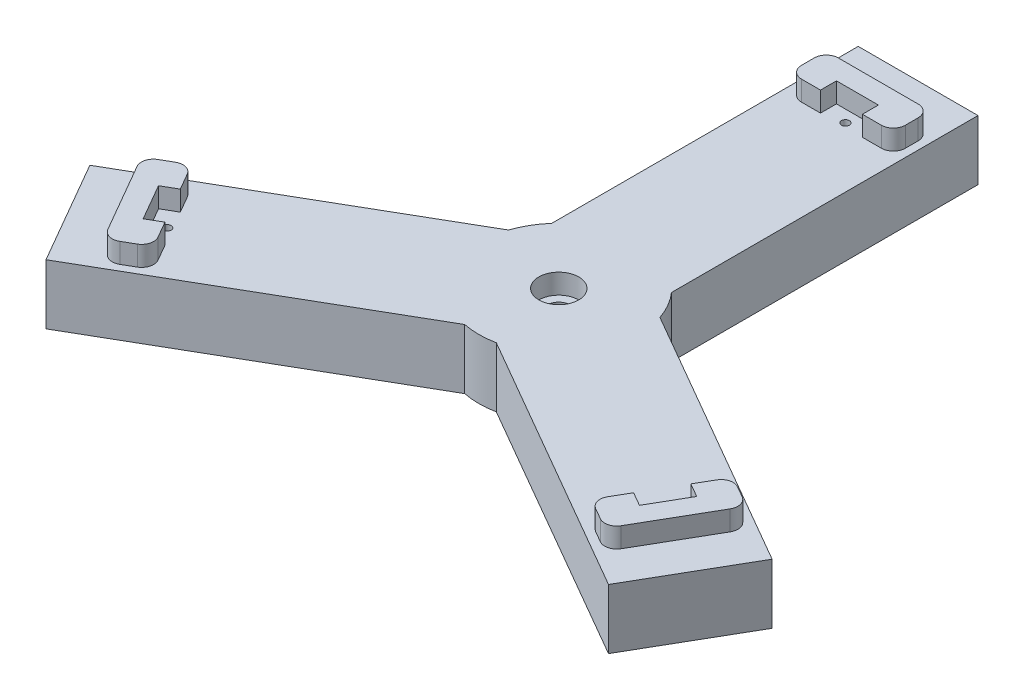
from build123d import *

# Parameters (mm, degrees)
SKETCH5_R                = 20
BOSS_EXTRUDE2_DEPTH      = 15
SKETCH6_W                = 30
SKETCH6_H                = 90
BOSS_EXTRUDE3_DEPTH      = 15
CIRPATTERN1_COUNT        = 3
BOSS_EXTRUDE4_DEPTH      = 5
FILLET1_R                = 3
SKETCH8_R                = 1
CUT_EXTRUDE1_DEPTH       = 16
SKETCH9_R                = 10
CUT_EXTRUDE2_DEPTH       = 10
CIRPATTERN4_COUNT        = 3
FILLET1_OF_CIRPATTERN4_R = 3
CIRPATTERN6_COUNT        = 3
CUT_EXTRUDE4_REACH       = 22
SKETCH11_R               = 2.875
SKETCH13_W               = 18
SKETCH13_H               = 18
CUT_EXTRUDE5_DEPTH       = 5
FILLET2_R                = 5
SKETCH14_R               = 5
CUT_EXTRUDE6_DEPTH       = 5


with BuildPart() as part:
    # Sketch5 → Boss-Extrude2 (new body)
    with BuildSketch(Plane(origin=(0, 0, 0), x_dir=(1, 0, 0), z_dir=(0, 1, 0))):
        Circle(SKETCH5_R)
    extrude(amount=BOSS_EXTRUDE2_DEPTH)

    # Sketch6 → Boss-Extrude3 (add)
    with BuildSketch(Plane(origin=(0, 0, 0), x_dir=(1, 0, 0), z_dir=(0, 1, 0))):
        with Locations((0, 45)):
            Rectangle(SKETCH6_W, SKETCH6_H)
    boss_extrude3 = extrude(amount=BOSS_EXTRUDE3_DEPTH)

    # CirPattern1: Boss-Extrude3 ×3 about axis
    cirpattern1_axis = Axis((0, 0, 0), (0, 1, 0))
    for i in range(1, CIRPATTERN1_COUNT):
        add(boss_extrude3.rotate(cirpattern1_axis, i * 360 / CIRPATTERN1_COUNT))

    # Sketch7 → Boss-Extrude4 (add)
    with BuildSketch(Plane(origin=(0, 15, 0), x_dir=(1, 0, 0), z_dir=(0, 1, 0))):
        Polygon((-13, 80), (13, 80), (13, 70.8), (5.25, 70.8), (5.25, 74.8), (-5.25, 74.8), (-5.25, 70.8), (-13, 70.8), align=None)
    boss_extrude4 = extrude(amount=BOSS_EXTRUDE4_DEPTH)

    # Fillet1
    fillet1_edges = [part.edges().sort_by_distance(p)[0] for p in [
        (-13, 17.5, -80),
        (-13, 17.5, -70.8),
        (13, 17.5, -70.8),
        (13, 17.5, -80),
    ]]
    fillet(fillet1_edges, radius=FILLET1_R)

    # Sketch8 → Cut-Extrude1 (cut, through all)
    with BuildSketch(Plane(origin=(0, 15, 0), x_dir=(1, 0, 0), z_dir=(0, 1, 0))):
        with Locations((0, 71.8)):
            Circle(SKETCH8_R)
    cut_extrude1 = extrude(amount=-CUT_EXTRUDE1_DEPTH, mode=Mode.SUBTRACT)

    # Sketch9 → Cut-Extrude2 (cut)
    with BuildSketch(Plane.XZ):
        with Locations((0, -71.8)):
            Circle(SKETCH9_R)
    cut_extrude2 = extrude(amount=-CUT_EXTRUDE2_DEPTH, mode=Mode.SUBTRACT)

    # CirPattern4: Boss-Extrude4 ×3 about axis
    cirpattern4_axis = Axis((0, 0, 0), (0, 1, 0))
    for i in range(1, CIRPATTERN4_COUNT):
        add(boss_extrude4.rotate(cirpattern4_axis, i * 360 / CIRPATTERN4_COUNT))

    # Fillet1 of CirPattern4
    fillet1_of_cirpattern4_edges = [part.edges().sort_by_distance(p)[0] for p in [
        (-62.782032303, 17.5, 51.258330249),
        (-54.814598588, 17.5, 46.658330249),
        (-67.814598588, 17.5, 24.141669751),
        (-75.782032303, 17.5, 28.741669751),
        (75.782032303, 17.5, 28.741669751),
        (67.814598588, 17.5, 24.141669751),
        (54.814598588, 17.5, 46.658330249),
        (62.782032303, 17.5, 51.258330249),
    ]]
    fillet(fillet1_of_cirpattern4_edges, radius=FILLET1_OF_CIRPATTERN4_R)

    # CirPattern6: Cut-Extrude1, Cut-Extrude2 ×3 about axis
    cirpattern6_axis = Axis((0, 0, 0), (0, 1, 0))
    for i in range(1, CIRPATTERN6_COUNT):
        add(cut_extrude1.rotate(cirpattern6_axis, i * 360 / CIRPATTERN6_COUNT), mode=Mode.SUBTRACT)
        add(cut_extrude2.rotate(cirpattern6_axis, i * 360 / CIRPATTERN6_COUNT), mode=Mode.SUBTRACT)

    # Sketch11 → Cut-Extrude4 (cut, up to next)
    with BuildSketch(Plane(origin=(0, 0, 0), x_dir=(1, 0, 0), z_dir=(0, 1, 0)), mode=Mode.PRIVATE) as cut_extrude4_sk1:
        Circle(SKETCH11_R)
    cut_extrude4_tool1 = extrude(cut_extrude4_sk1.sketch, amount=CUT_EXTRUDE4_REACH, mode=Mode.PRIVATE) & part.part
    add(cut_extrude4_tool1.solids().sort_by_distance((0, 0, 0))[0], mode=Mode.SUBTRACT)

    # Sketch13 → Cut-Extrude5 (cut)
    with BuildSketch(Plane.XZ):
        Rectangle(SKETCH13_W, SKETCH13_H)
    extrude(amount=-CUT_EXTRUDE5_DEPTH, mode=Mode.SUBTRACT)

    # Fillet2
    fillet2_edges = [part.edges().sort_by_distance(p)[0] for p in [
        (9, 2.5, 9),
        (9, 2.5, -9),
        (-9, 2.5, -9),
        (-9, 2.5, 9),
    ]]
    fillet(fillet2_edges, radius=FILLET2_R)

    # Sketch14 → Cut-Extrude6 (cut)
    with BuildSketch(Plane(origin=(0, 15, 0), x_dir=(1, 0, 0), z_dir=(0, 1, 0))):
        Circle(SKETCH14_R)
    extrude(amount=-CUT_EXTRUDE6_DEPTH, mode=Mode.SUBTRACT)


solid = part.part
